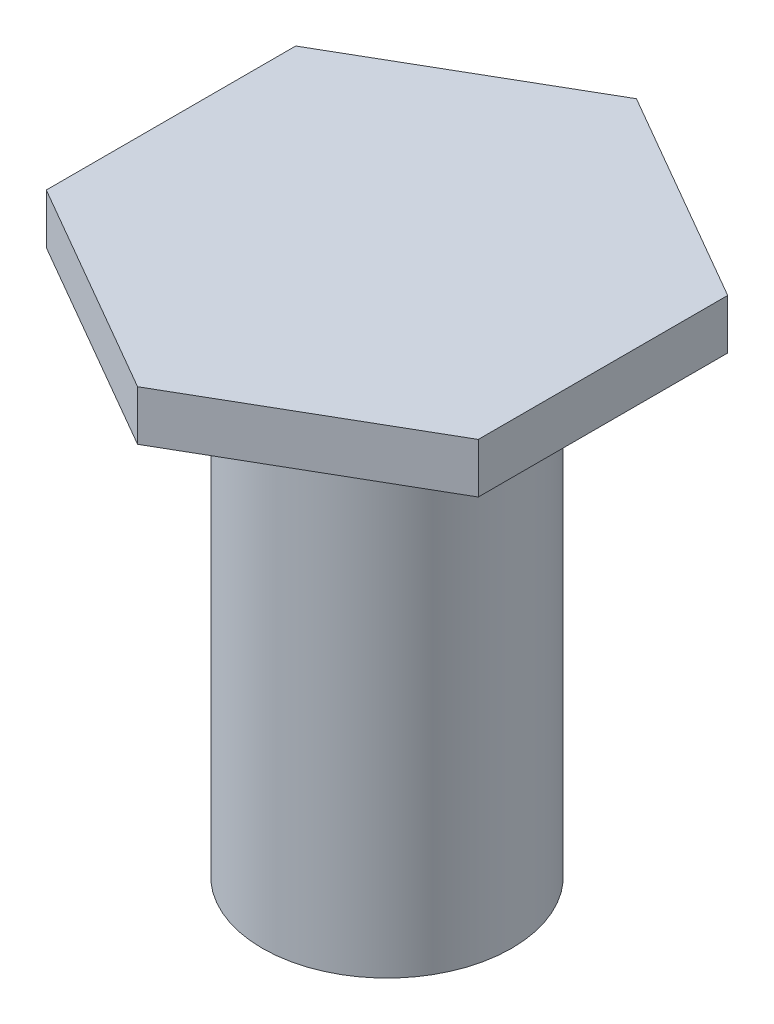
from build123d import *

# Parameters (mm, degrees)
SKETCH1_R           = 5
BOSS_EXTRUDE1_DEPTH = 20
SKETCH2_R           = 10
BOSS_EXTRUDE2_DEPTH = 2
SKETCH3_OUTSIDE_W   = 29.166
SKETCH3_OUTSIDE_H   = 29.166
CUT_EXTRUDE1_DEPTH  = 2


with BuildPart() as part:
    # Sketch1 → Boss-Extrude1 (new body)
    with BuildSketch(Plane(origin=(0, 0, 0), x_dir=(1, 0, 0), z_dir=(0, 1, 0))):
        Circle(SKETCH1_R)
    extrude(amount=BOSS_EXTRUDE1_DEPTH)

    # Sketch2 → Boss-Extrude2 (add)
    with BuildSketch(Plane(origin=(0, 20, 0), x_dir=(1, 0, 0), z_dir=(0, 1, 0))):
        Circle(SKETCH2_R)
    extrude(amount=BOSS_EXTRUDE2_DEPTH)

    # Sketch3 outside → Cut-Extrude1 (cut)
    with BuildSketch(Plane(origin=(0, 22, 0), x_dir=(1, 0, 0), z_dir=(0, 1, 0))):
        Rectangle(SKETCH3_OUTSIDE_W, SKETCH3_OUTSIDE_H)
        Polygon((0, 10), (8.660254038, 5), (8.660254038, -5), (0, -10), (-8.660254038, -5), (-8.660254038, 5), align=None, mode=Mode.SUBTRACT)
    extrude(amount=-CUT_EXTRUDE1_DEPTH, mode=Mode.SUBTRACT)


solid = part.part
